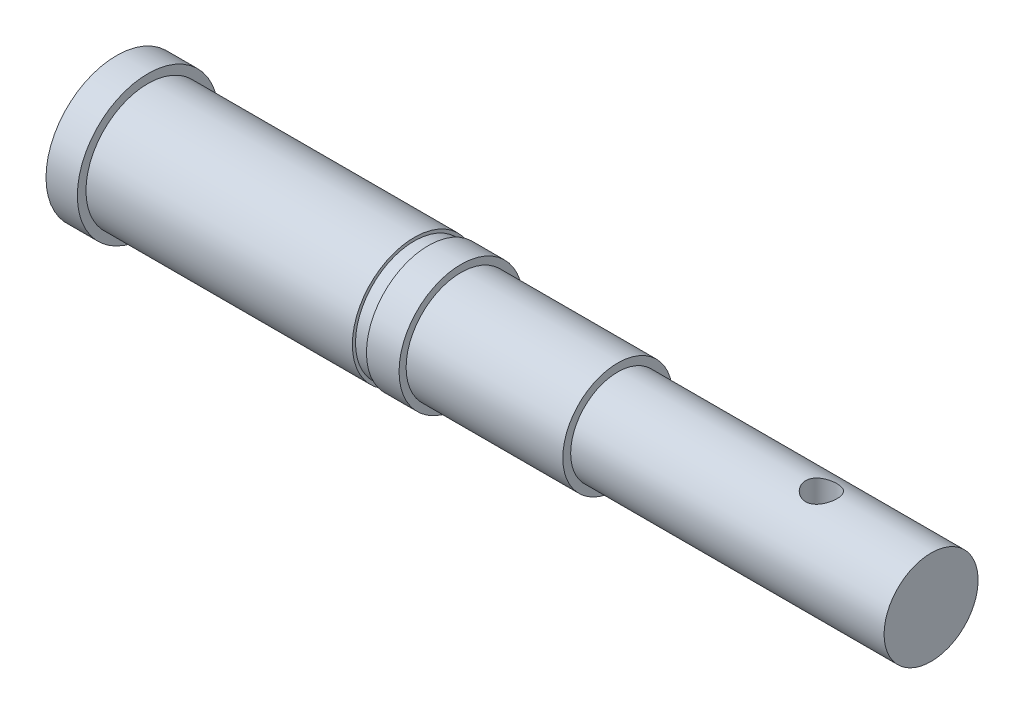
from build123d import *

# Parameters (mm, degrees)
SKETCH_2_R          = 1
CUT_EXTRUDE_1_DEPTH = 5


with BuildPart() as part:
    # 草图1 → 旋转1 (revolve)
    with BuildSketch(Plane.XY):
        Polygon((-33.409090909, 0), (18.570909091, 0), (18.570909091, 3), (-1.429090909, 3), (-1.429090909, 3.5), (-11.429090909, 3.5), (-11.429090909, 3.95), (-13.509090909, 3.95), (-13.509090909, 3.75), (-14.409090909, 3.75), (-14.409090909, 3.95), (-31.409090909, 3.95), (-31.409090909, 4.5), (-33.409090909, 4.5), align=None)
    revolve(axis=Axis((-66.136363636, 0, 0), (1, 0, 0)))

    # 草图2 → 切除-拉伸1 (cut, symmetric)
    with BuildSketch(Plane(origin=(0, 0, 0), x_dir=(1, 0, 0), z_dir=(0, 1, 0))):
        with Locations((11.570909091, 0)):
            Circle(SKETCH_2_R)
    extrude(amount=CUT_EXTRUDE_1_DEPTH, both=True, mode=Mode.SUBTRACT)


solid = part.part
